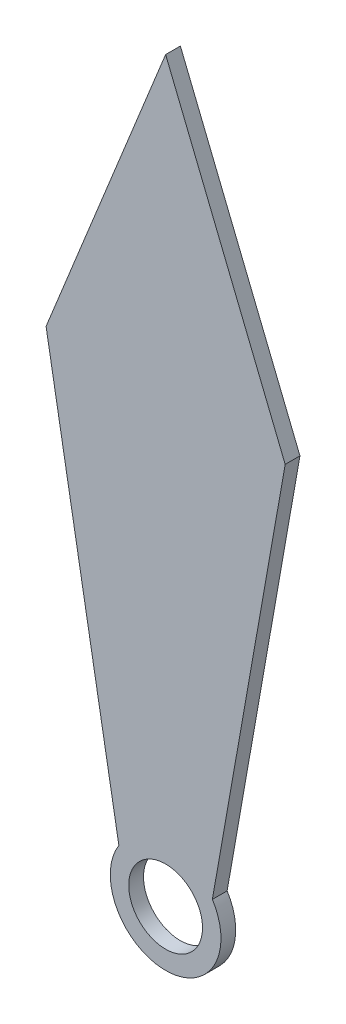
from build123d import *

# Parameters (mm, degrees)
CROQUIS1_R              = 0.5
SALIENTE_EXTRUIR2_DEPTH = 0.2


with BuildPart() as part:
    # Croquis1 → Saliente-Extruir2 (new body)
    with BuildSketch(Plane.XY):
        with BuildLine():
            Line((-1.620168748, 6), (-0.633616905, 0.401284958))
            ThreePointArc((-0.633616905, 0.401284958), (0, -0.75), (0.633616905, 0.401284958))
            Line((0.633616905, 0.401284958), (1.620168748, 6))
            Line((1.620168748, 6), (0, 10))
            Line((0, 10), (-1.620168748, 6))
        make_face()
        Circle(CROQUIS1_R, mode=Mode.SUBTRACT)
    extrude(amount=SALIENTE_EXTRUIR2_DEPTH)


solid = part.part
